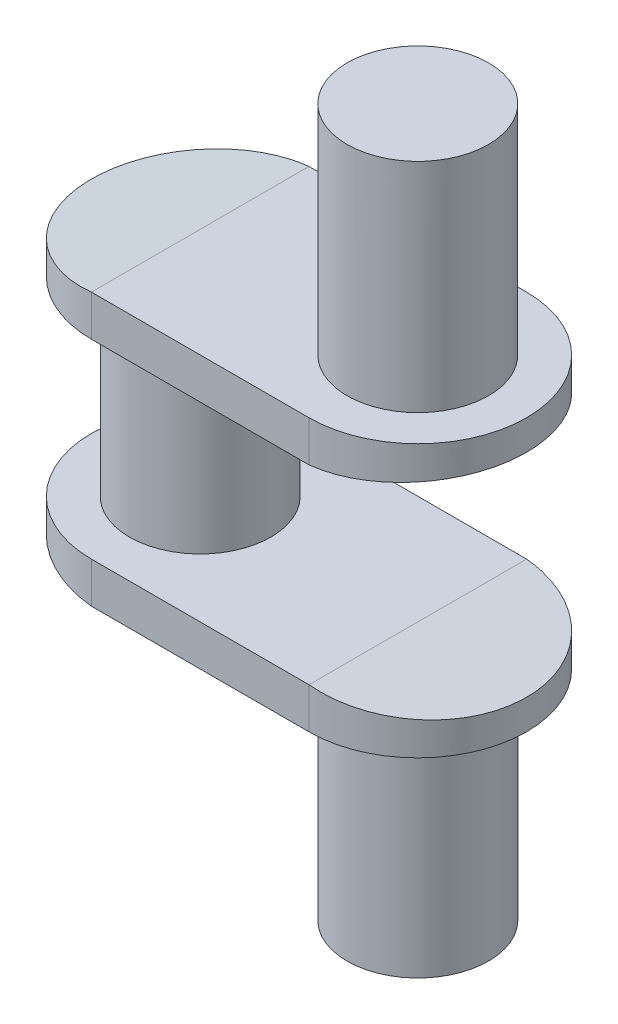
from build123d import *

# Parameters (mm, degrees)
SKETCH1_R               = 26
BOSS_EXTRUDE1_DEPTH     = 35
BOSS_EXTRUDE2_DEPTH     = 15
SKETCH5_R               = 26
BOSS_EXTRUDE3_DEPTH     = 80
CUT_EXTRUDE2_DEPTH      = 41
CUT_EXTRUDE2_DEPTH_BACK = 41


with BuildPart() as part:
    # Sketch1 → Boss-Extrude1 (new body, symmetric)
    with BuildSketch(Plane(origin=(0, 0, 0), x_dir=(1, 0, 0), z_dir=(0, 1, 0))):
        Circle(SKETCH1_R)
    extrude(amount=BOSS_EXTRUDE1_DEPTH, both=True)

    # Sketch3 → Boss-Extrude2 (add)
    with BuildSketch(Plane(origin=(0, 35, 0), x_dir=(1, 0, 0), z_dir=(0, 1, 0))):
        with BuildLine():
            Line((0, 40), (80, 40))
            ThreePointArc((80, 40), (120, 0), (80, -40))
            Line((80, -40), (0, -40))
            ThreePointArc((0, -40), (-40, 0), (0, 40))
        make_face()
    boss_extrude2 = extrude(amount=BOSS_EXTRUDE2_DEPTH)

    # Mirror2: Boss-Extrude2 across plane
    add(boss_extrude2.mirror(Plane.ZX))

    # Sketch5 → Boss-Extrude3 (add)
    with BuildSketch(Plane(origin=(0, 50, 0), x_dir=(1, 0, 0), z_dir=(0, 1, 0))):
        with Locations((80, 0)):
            Circle(SKETCH5_R)
    boss_extrude3 = extrude(amount=BOSS_EXTRUDE3_DEPTH)

    # Mirror3: Boss-Extrude3 across plane
    add(boss_extrude3.mirror(Plane.ZX))

    # Sketch6 → Cut-Extrude2 (cut, two sides)
    with BuildSketch(Plane.XY) as cut_extrude2_sk:
        Polygon((0, -50), (-40, -50), (-40, -46), align=None)
        Polygon((80, -35), (120, -35), (120, -39), align=None)
        Polygon((120, 39), (80, 35), (120, 35), align=None)
        Polygon((-40, 46), (0, 50), (-40, 50), align=None)
    extrude(amount=CUT_EXTRUDE2_DEPTH, mode=Mode.SUBTRACT)
    extrude(cut_extrude2_sk.sketch, amount=-CUT_EXTRUDE2_DEPTH_BACK, mode=Mode.SUBTRACT)


solid = part.part
